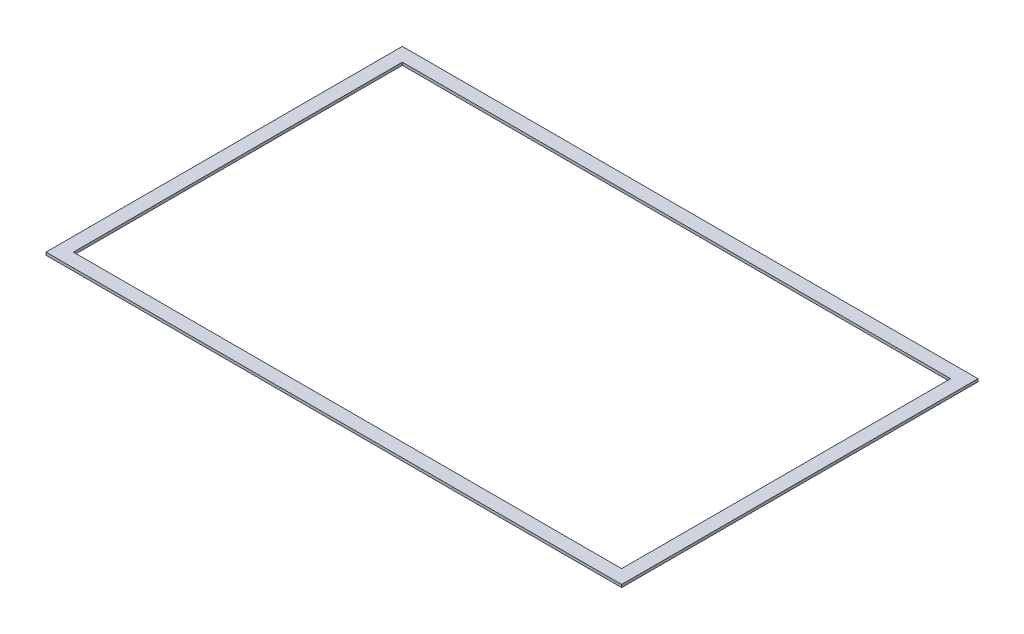
from build123d import *

# Parameters (mm, degrees)
SKETCH1_W           = 210
SKETCH1_H           = 130
SKETCH1_W_2         = 200
SKETCH1_H_2         = 120
BOSS_EXTRUDE1_DEPTH = 1


with BuildPart() as part:
    # Sketch1 → Boss-Extrude1 (new body)
    with BuildSketch(Plane(origin=(0, 0, 0), x_dir=(1, 0, 0), z_dir=(0, 1, 0))):
        Rectangle(SKETCH1_W, SKETCH1_H)
        Rectangle(SKETCH1_W_2, SKETCH1_H_2, mode=Mode.SUBTRACT)
    extrude(amount=BOSS_EXTRUDE1_DEPTH)


solid = part.part
